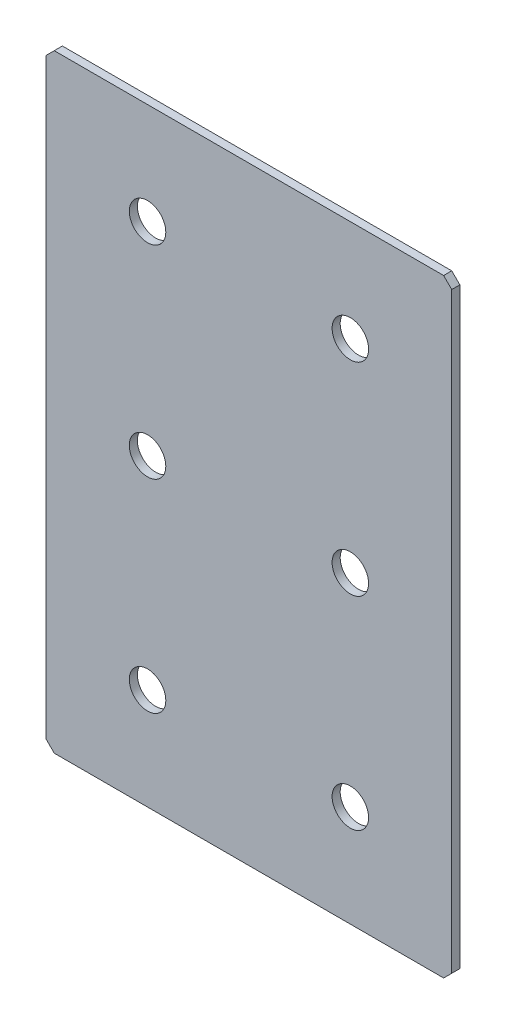
from build123d import *

# Parameters (mm, degrees)
SKETCH_1_W        = 100
SKETCH_1_H        = 150
EXTRUDE_1_DEPTH   = 2
CHAMFER_1_SIZE    = 2
HOLE_WIZARD_M81_D = 9


with BuildPart() as part:
    # Эскиз1 → Бобышка-Вытянуть1 (new body)
    with BuildSketch(Plane.XY):
        Rectangle(SKETCH_1_W, SKETCH_1_H)
    extrude(amount=EXTRUDE_1_DEPTH)

    # Фаска1
    chamfer_1_edges = [part.edges().sort_by_distance(p)[0] for p in [
        (50, -75, 1),
        (-50, -75, 1),
        (-50, 75, 1),
        (50, 75, 1),
    ]]
    chamfer(chamfer_1_edges, length=CHAMFER_1_SIZE)

    # Отверстие с зазором M81 (through all)
    with Locations(Plane.XY.offset(2)):
        with Locations((-25, 50), (25, 50), (25, 0), (-25, 0), (-25, -50), (25, -50)):
            Hole(HOLE_WIZARD_M81_D / 2)


solid = part.part
